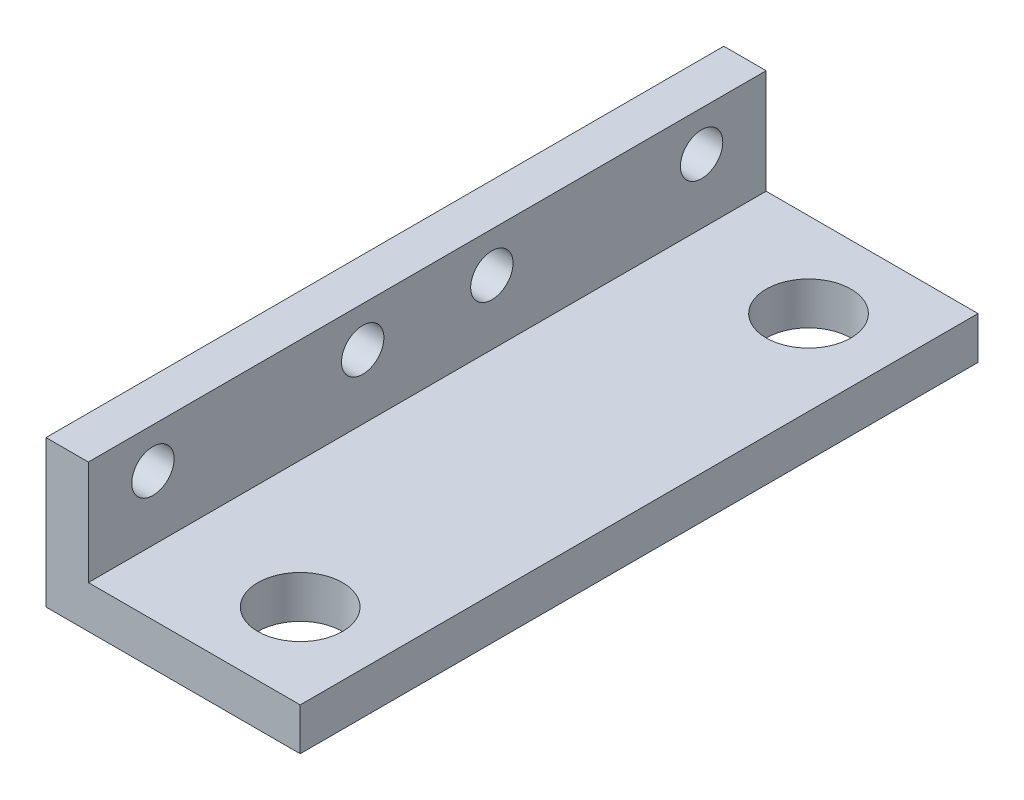
from build123d import *

# Parameters (mm, degrees)
BOSS_EXTRUDE1_DEPTH = 50.8
SKETCH2_R           = 1.5875
CUT_EXTRUDE1_DEPTH  = 10
SKETCH5_R           = 3.175
CUT_EXTRUDE2_DEPTH  = 6.35


with BuildPart() as part:
    # Sketch1 → Boss-Extrude1 (new body)
    with BuildSketch(Plane.XY):
        Polygon((0, 0), (0, 11), (3.175, 11), (3.175, 3.175), (19.05, 3.175), (19.05, 0), align=None)
    extrude(amount=BOSS_EXTRUDE1_DEPTH)

    # Sketch2 → Cut-Extrude1 (cut)
    with BuildSketch(Plane(origin=(3.175, 0, 0), x_dir=(0, 0, -1), z_dir=(1, 0, 0))):
        with Locations((-45.96, 8)):
            Circle(SKETCH2_R)
        with Locations((-30.24, 8)):
            Circle(SKETCH2_R)
        with Locations((-20.56, 8)):
            Circle(SKETCH2_R)
        with Locations((-4.84, 8)):
            Circle(SKETCH2_R)
    extrude(amount=-CUT_EXTRUDE1_DEPTH, mode=Mode.SUBTRACT)

    # Sketch5 → Cut-Extrude2 (cut)
    with BuildSketch(Plane(origin=(0, 3.175, 0), x_dir=(1, 0, 0), z_dir=(0, 1, 0))):
        with Locations((12.7, -6.35)):
            Circle(SKETCH5_R)
        with Locations((12.7, -44.45)):
            Circle(SKETCH5_R)
    extrude(amount=-CUT_EXTRUDE2_DEPTH, mode=Mode.SUBTRACT)


solid = part.part
